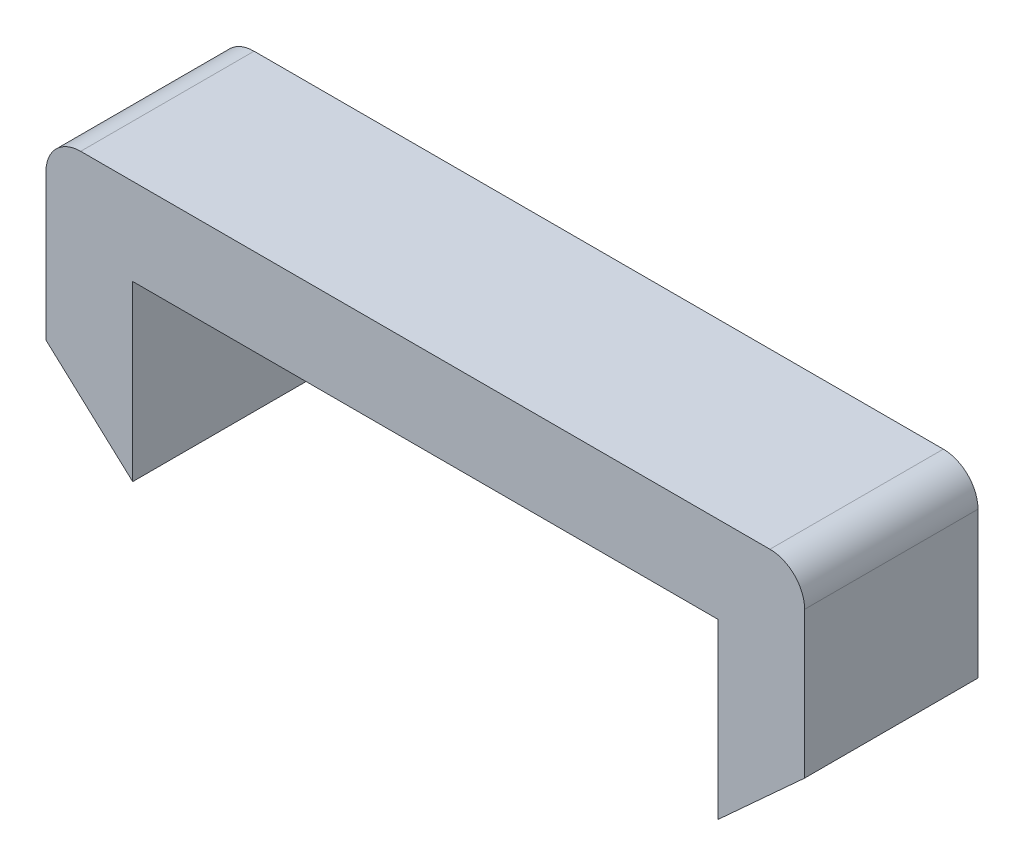
from build123d import *

# Parameters (mm, degrees)
EXTRUDE_1_DEPTH     = 10
FILLET_1_R          = 2
CUT_EXTRUDE_1_DEPTH = 11
CUT_EXTRUDE_2_DEPTH = 11


with BuildPart() as part:
    # 草图1 → 凸台-拉伸1 (new body)
    with BuildSketch(Plane.XY):
        Polygon((-26.953865184, 1.151568381), (-21.953865184, 1.151568381), (-21.953865184, 11.151568381), (11.796134816, 11.151568381), (11.796134816, 1.151568381), (16.796134816, 1.151568381), (16.796134816, 16.151568381), (-26.953865184, 16.151568381), align=None)
    extrude(amount=EXTRUDE_1_DEPTH)

    # 圆角1
    fillet_1_edges = [part.edges().sort_by_distance(p)[0] for p in [
        (-26.953865184, 16.151568381, 5),
        (16.796134816, 16.151568381, 5),
    ]]
    fillet(fillet_1_edges, radius=FILLET_1_R)

    # 草图2 → 切除-拉伸1 (cut, through all)
    with BuildSketch(Plane.XY.offset(10)):
        Polygon((-26.953865184, 1.151568381), (-21.953865184, 1.151568381), (-26.953865184, 5.718181818), align=None)
    extrude(amount=-CUT_EXTRUDE_1_DEPTH, mode=Mode.SUBTRACT)

    # 草图3 → 切除-拉伸2 (cut, through all)
    with BuildSketch(Plane.XY.offset(10)):
        Polygon((16.796134816, 5.718181818), (11.796134816, 1.151568381), (16.796134816, 1.151568381), align=None)
    extrude(amount=-CUT_EXTRUDE_2_DEPTH, mode=Mode.SUBTRACT)


solid = part.part
